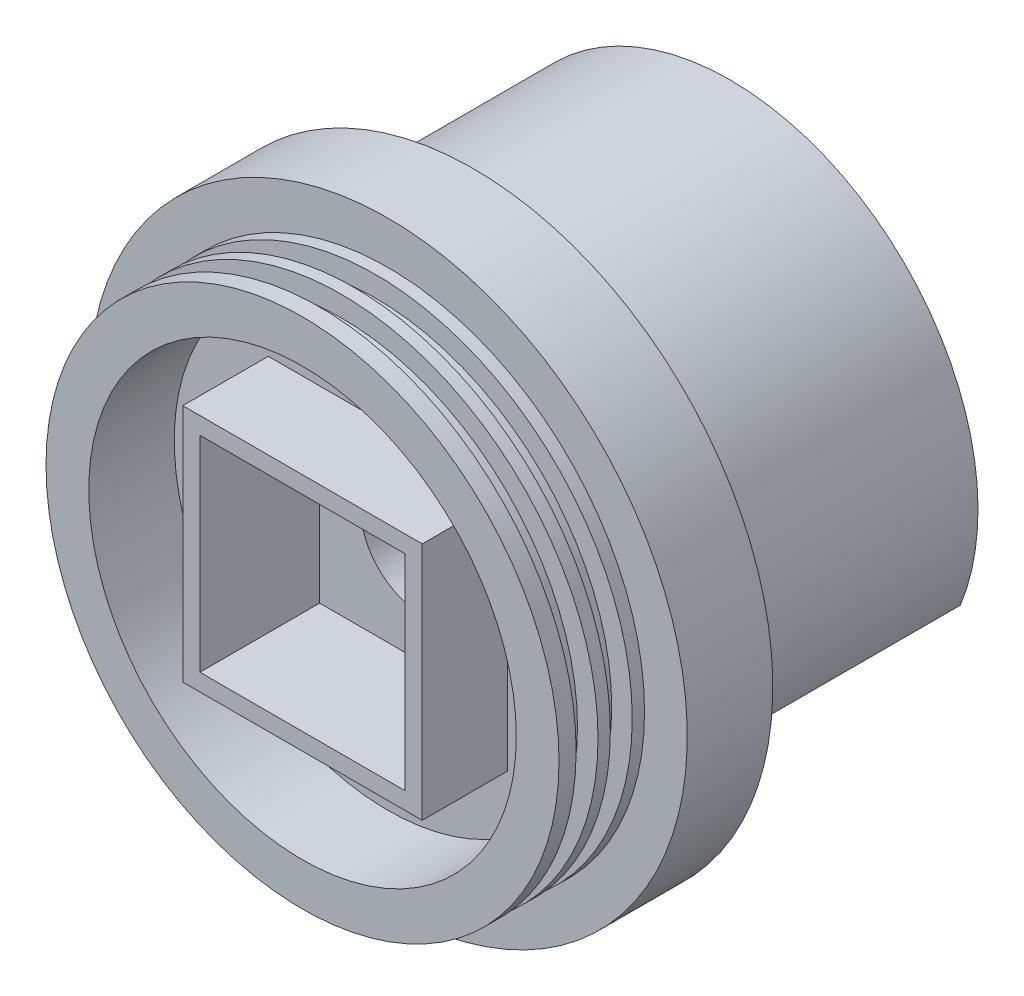
from build123d import *

# Parameters (mm, degrees)
SKETCH1_R           = 38.1
BOSS_EXTRUDE1_DEPTH = 12.7
SKETCH3_R           = 44.45
BOSS_EXTRUDE2_DEPTH = 12.7
SKETCH4_R           = 9.144
CUT_EXTRUDE1_DEPTH  = 26.4
SKETCH5_W           = 30.48
SKETCH5_H           = 30.48
CUT_EXTRUDE2_DEPTH  = 17.78
SKETCH6_R           = 31.75
CUT_EXTRUDE3_DEPTH  = 12.7
BOSS_EXTRUDE3_DEPTH = 38.1
CUT_EXTRUDE4_START  = -2.54
SKETCH8_R           = 38.1
SKETCH8_R_2         = 35.052
CUT_EXTRUDE4_DEPTH  = 3.2512
CUT_EXTRUDE5_START  = -7.62
SKETCH9_R           = 38.1
SKETCH9_R_2         = 35.052
CUT_EXTRUDE5_DEPTH  = 3.2512
FILLET1_R           = 2.54
SKETCH10_W          = 35.56
SKETCH10_H          = 35.56
SKETCH10_W_2        = 30.48
SKETCH10_H_2        = 30.48
BOSS_EXTRUDE4_DEPTH = 12.7


with BuildPart() as part:
    # Sketch1 → Boss-Extrude1 (new body)
    with BuildSketch(Plane.XY):
        Circle(SKETCH1_R)
    extrude(amount=BOSS_EXTRUDE1_DEPTH)

    # Sketch3 → Boss-Extrude2 (add)
    with BuildSketch(Plane(origin=(0, 0, 0), x_dir=(-1, 0, 0), z_dir=(0, 0, -1))):
        Circle(SKETCH3_R)
    extrude(amount=BOSS_EXTRUDE2_DEPTH)

    # Sketch4 → Cut-Extrude1 (cut, through all)
    with BuildSketch(Plane(origin=(0, 0, -12.7), x_dir=(-1, 0, 0), z_dir=(0, 0, -1))):
        Circle(SKETCH4_R)
    extrude(amount=-CUT_EXTRUDE1_DEPTH, mode=Mode.SUBTRACT)

    # Sketch5 → Cut-Extrude2 (cut)
    with BuildSketch(Plane.XY.offset(12.7)):
        Rectangle(SKETCH5_W, SKETCH5_H)
    extrude(amount=-CUT_EXTRUDE2_DEPTH, mode=Mode.SUBTRACT)

    # Sketch6 → Cut-Extrude3 (cut)
    with BuildSketch(Plane.XY.offset(12.7)):
        Circle(SKETCH6_R)
    extrude(amount=-CUT_EXTRUDE3_DEPTH, mode=Mode.SUBTRACT)

    # Sketch7 → Boss-Extrude3 (add)
    with BuildSketch(Plane(origin=(0, 0, -12.7), x_dir=(-1, 0, 0), z_dir=(0, 0, -1))):
        with BuildLine():
            Line((-34.21134801, -13.639375622), (-31.460634651, -13.639375622))
            ThreePointArc((-31.460634651, -13.639375622), (0, 34.29), (31.460634651, -13.639375622))
            Line((31.460634651, -13.639375622), (34.21134801, -13.639375622))
            ThreePointArc((34.21134801, -13.639375622), (0, 36.83), (-34.21134801, -13.639375622))
        make_face()
    extrude(amount=BOSS_EXTRUDE3_DEPTH)

    # Sketch8 → Cut-Extrude4 (cut)
    with BuildSketch(Plane.XY.offset(12.7).offset(CUT_EXTRUDE4_START)):
        Circle(SKETCH8_R)
        Circle(SKETCH8_R_2, mode=Mode.SUBTRACT)
    extrude(amount=-CUT_EXTRUDE4_DEPTH, mode=Mode.SUBTRACT)

    # Sketch9 → Cut-Extrude5 (cut)
    with BuildSketch(Plane.XY.offset(12.7).offset(CUT_EXTRUDE5_START)):
        Circle(SKETCH9_R)
        Circle(SKETCH9_R_2, mode=Mode.SUBTRACT)
    extrude(amount=-CUT_EXTRUDE5_DEPTH, mode=Mode.SUBTRACT)

    # Fillet1
    fillet1_edges = [part.edges().sort_by_distance(p)[0] for p in [
        (0, 36.83, -12.7),
        (32.835991331, -13.639375622, -12.7),
        (0, 34.29, -12.7),
        (-32.835991331, -13.639375622, -12.7),
    ]]
    fillet(fillet1_edges, radius=FILLET1_R)

    # Sketch10 → Boss-Extrude4 (add)
    with BuildSketch(Plane.XY):
        Rectangle(SKETCH10_W, SKETCH10_H)
        Rectangle(SKETCH10_W_2, SKETCH10_H_2, mode=Mode.SUBTRACT)
    extrude(amount=BOSS_EXTRUDE4_DEPTH)


solid = part.part
